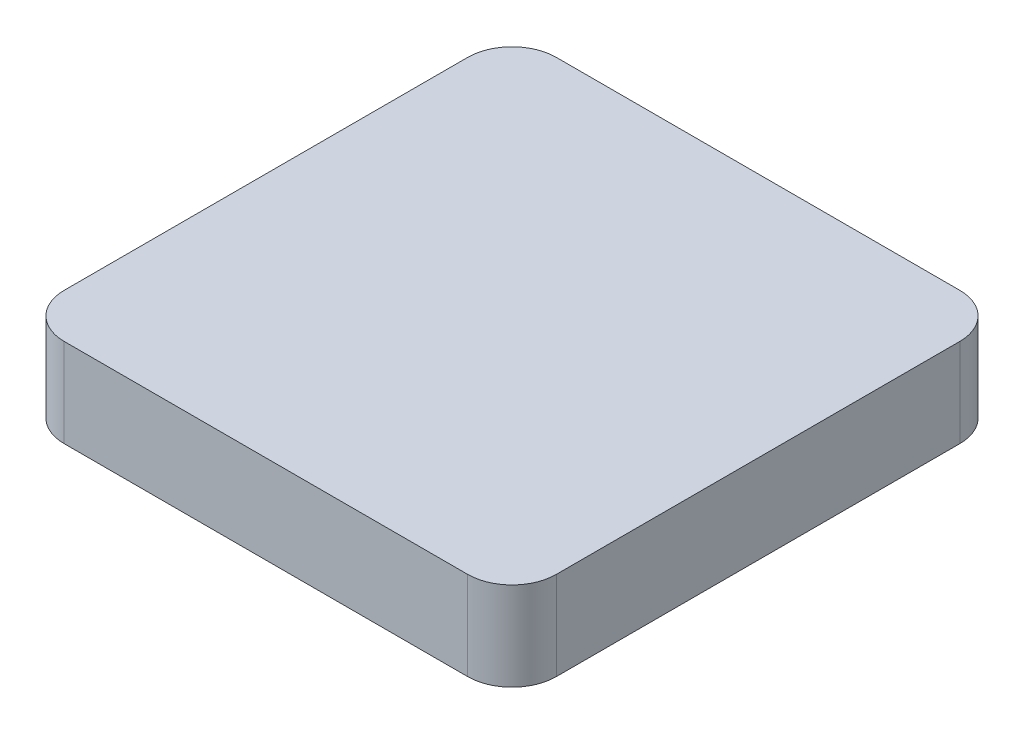
from build123d import *

# Parameters (mm, degrees)
SKETCH2_W           = 33.333333333
SKETCH2_H           = 33.333333333
BOSS_EXTRUDE1_DEPTH = 6
FILLET1_R           = 3
SCALE1_SCALE        = 7.5


with BuildPart() as part:
    # Sketch2 → Boss-Extrude1 (new body)
    with BuildSketch(Plane(origin=(0, 0, 0), x_dir=(1, 0, 0), z_dir=(0, 1, 0))):
        with Locations((16.666666666, 16.666666666)):
            Rectangle(SKETCH2_W, SKETCH2_H)
    extrude(amount=BOSS_EXTRUDE1_DEPTH)

    # Fillet1
    fillet1_edges = [part.edges().sort_by_distance(p)[0] for p in [
        (0, 3, -33.333333333),
        (33.333333333, 3, -33.333333333),
        (33.333333333, 3, 0),
        (0, 3, 0),
    ]]
    fillet(fillet1_edges, radius=FILLET1_R)


with BuildPart() as part_1:
    # Scale1: scaled about (16.666666667, 3, -16.666666667)
    add(part.part.scale(SCALE1_SCALE).moved(Location((-108.333333336, -19.5, 108.333333336))))


solid = part_1.part
